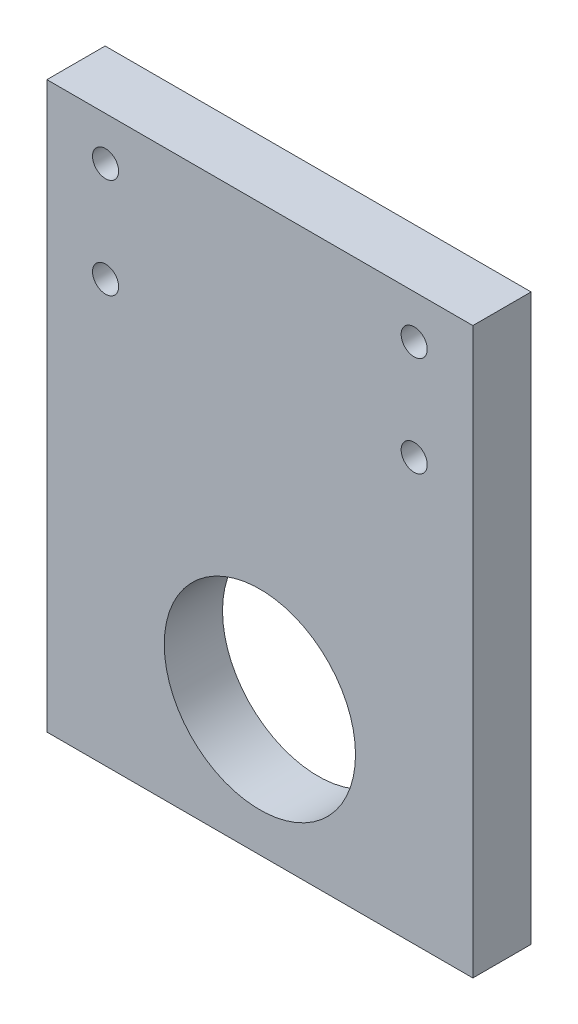
from build123d import *

# Parameters (mm, degrees)
SKETCH1_W           = 49
SKETCH1_H           = 65
SKETCH1_R           = 1.5
SKETCH1_R_2         = 11
BOSS_EXTRUDE1_DEPTH = 6.7


with BuildPart() as part:
    # Sketch1 → Boss-Extrude1 (new body)
    with BuildSketch(Plane.XY):
        with Locations((24.5, 32.5)):
            Rectangle(SKETCH1_W, SKETCH1_H)
        with Locations((6.75, 60)):
            Circle(SKETCH1_R, mode=Mode.SUBTRACT)
        with Locations((6.75, 48.5)):
            Circle(SKETCH1_R, mode=Mode.SUBTRACT)
        with Locations((42.25, 60)):
            Circle(SKETCH1_R, mode=Mode.SUBTRACT)
        with Locations((42.25, 48.5)):
            Circle(SKETCH1_R, mode=Mode.SUBTRACT)
        with Locations((24.5, 15.5)):
            Circle(SKETCH1_R_2, mode=Mode.SUBTRACT)
    extrude(amount=BOSS_EXTRUDE1_DEPTH)


solid = part.part
